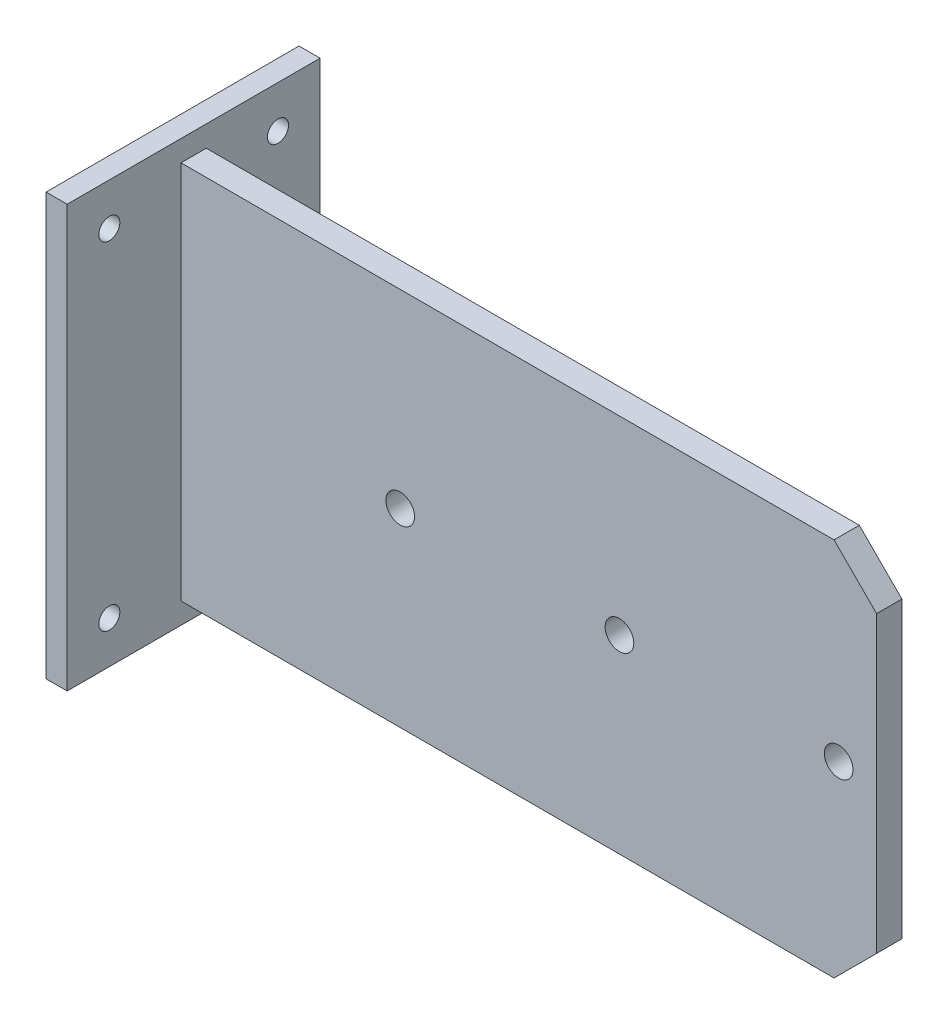
from build123d import *

# Parameters (mm, degrees)
SKETCH1_W           = 127
SKETCH1_H           = 2540
BOSS_EXTRUDE1_DEPTH = 762
SKETCH2_W           = 4191
SKETCH2_H           = 2286
BOSS_EXTRUDE2_DEPTH = 76.2
SKETCH3_R           = 63.5
CUT_EXTRUDE1_DEPTH  = 152.4
SKETCH4_R           = 86.36
CUT_EXTRUDE2_DEPTH  = 839.2
CHAMFER1_SIZE       = 256.54


with BuildPart() as part:
    # Sketch1 → Boss-Extrude1 (new body, symmetric)
    with BuildSketch(Plane.XY):
        Rectangle(SKETCH1_W, SKETCH1_H)
    extrude(amount=BOSS_EXTRUDE1_DEPTH, both=True)

    # Sketch2 → Boss-Extrude2 (add, symmetric)
    with BuildSketch(Plane.XY):
        with Locations((2159, 0)):
            Rectangle(SKETCH2_W, SKETCH2_H)
    extrude(amount=BOSS_EXTRUDE2_DEPTH, both=True)

    # Sketch3 → Cut-Extrude1 (cut)
    with BuildSketch(Plane.ZY.offset(63.5)):
        with Locations((-508, 1016)):
            Circle(SKETCH3_R)
        with Locations((-508, -1016)):
            Circle(SKETCH3_R)
        with Locations((508, -1016)):
            Circle(SKETCH3_R)
        with Locations((508, 1016)):
            Circle(SKETCH3_R)
    extrude(amount=-CUT_EXTRUDE1_DEPTH, mode=Mode.SUBTRACT)

    # Sketch4 → Cut-Extrude2 (cut, through all)
    with BuildSketch(Plane.XY.offset(76.2)):
        with Locations((4025.9, 0)):
            Circle(SKETCH4_R)
        with Locations((2705.1, 0)):
            Circle(SKETCH4_R)
        with Locations((1384.3, 0)):
            Circle(SKETCH4_R)
    extrude(amount=-CUT_EXTRUDE2_DEPTH, mode=Mode.SUBTRACT)

    # Chamfer1
    chamfer1_edges = [part.edges().sort_by_distance(p)[0] for p in [
        (4254.5, -1143, 0),
        (4254.5, 1143, 0),
    ]]
    chamfer(chamfer1_edges, length=CHAMFER1_SIZE)


solid = part.part
